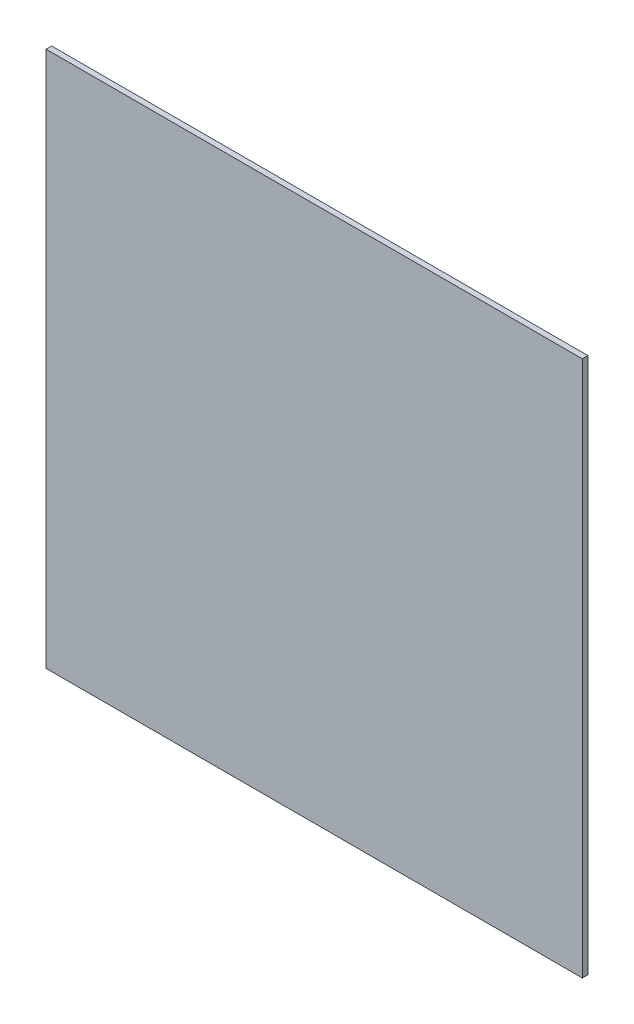
from build123d import *

# Parameters (mm, degrees)
SKETCH1_W           = 609.6
SKETCH1_H           = 609.6
BOSS_EXTRUDE1_DEPTH = 6.35


with BuildPart() as part:
    # Sketch1 → Boss-Extrude1 (new body)
    with BuildSketch(Plane.XY):
        with Locations((-304.8, 304.8)):
            Rectangle(SKETCH1_W, SKETCH1_H)
    extrude(amount=BOSS_EXTRUDE1_DEPTH)


solid = part.part
